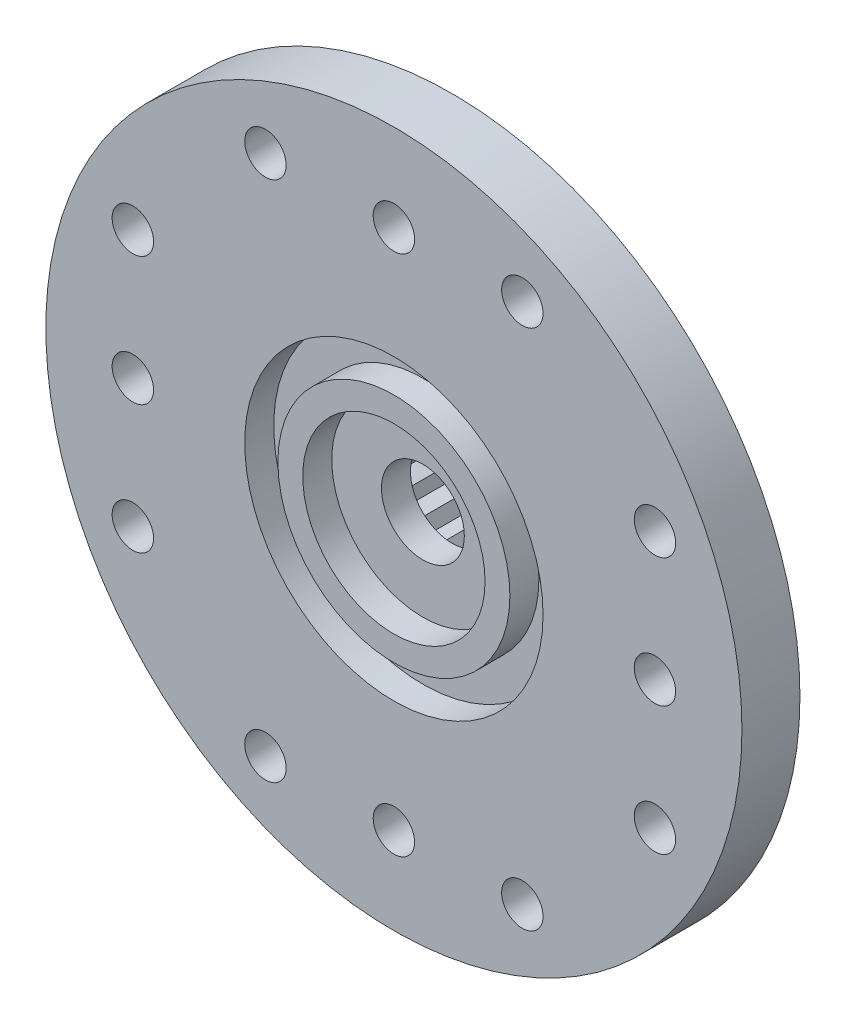
from build123d import *

# Parameters (mm, degrees)
SKETCH1_R           = 4.5000037
BOSS_EXTRUDE1_DEPTH = 3.75000012
SKETCH2_R           = 4.5000037
SKETCH2_R_2         = 3.499999998
SKETCH2_R_3         = 1.25000004
BOSS_EXTRUDE2_DEPTH = 1.750000056
SKETCH4_R           = 2.75000466
SKETCH4_R_2         = 1.25000004
CUT_EXTRUDE1_DEPTH  = 0.875000028
SKETCH6_R           = 4.5000037
SKETCH6_R_2         = 3.5000057
CUT_EXTRUDE2_DEPTH  = 0.875000028
SKETCH7_R           = 10.5000044
SKETCH7_R_2         = 4.5000037
BOSS_EXTRUDE3_DEPTH = 1.750000056
SKETCH9_R           = 0.62500002
CUT_EXTRUDE3_DEPTH  = 6.500000176
CIRPATTERN1_COUNT   = 4
CHAMFER1_SIZE       = 0.999998
CHAMFER1_SIZE2      = 0.577349114


with BuildPart() as part:
    # Sketch1 → Boss-Extrude1 (new body)
    with BuildSketch(Plane.XY):
        with Locations((-10.24995918, 0)):
            Circle(SKETCH1_R)
        Polygon((-10.24995918, 2.999994), (-10.594624819, 2.728309468), (-10.996027349, 2.905743672), (-11.262299488, 2.55687975), (-11.695217312, 2.628914782), (-11.866365092, 2.224791874), (-12.303596391, 2.186901508), (-12.368865968, 1.752912142), (-12.782937891, 1.60747717), (-12.738228138, 1.170890494), (-13.103123023, 0.927049129), (-12.951243218, 0.515297489), (-13.244033377, 0.188371182), (-12.994526687, -0.172673551), (-13.196815038, -0.562142819), (-12.865358886, -0.849794878), (-12.964434908, -1.27733532), (-12.571855902, -1.473520467), (-12.561494285, -1.912268145), (-12.132459609, -2.004659346), (-12.01331141, -2.427046129), (-11.574778889, -2.409838105), (-11.354330629, -2.789323879), (-10.933854876, -2.663597874), (-10.625958129, -2.976338151), (-10.24995918, -2.749993992), (-9.873960231, -2.976338151), (-9.566063484, -2.663597874), (-9.145587731, -2.789323879), (-8.925139471, -2.409838105), (-8.48660695, -2.427046129), (-8.367458751, -2.004659346), (-7.938424075, -1.912268145), (-7.928062458, -1.473520467), (-7.535483452, -1.27733532), (-7.634559474, -0.849794878), (-7.303103322, -0.562142819), (-7.505391673, -0.172673551), (-7.255884983, 0.188371182), (-7.548675142, 0.515297489), (-7.396795337, 0.927049129), (-7.761690222, 1.170890494), (-7.716980469, 1.60747717), (-8.131052392, 1.752912142), (-8.196321969, 2.186901508), (-8.633553268, 2.224791874), (-8.804701048, 2.628914782), (-9.237618872, 2.55687975), (-9.503891011, 2.905743672), (-9.905293541, 2.728309468), align=None, mode=Mode.SUBTRACT)
    extrude(amount=-BOSS_EXTRUDE1_DEPTH)

    # Sketch2 → Boss-Extrude2 (add)
    with BuildSketch(Plane.XY):
        with Locations((-10.24995918, 0)):
            Circle(SKETCH2_R)
        with Locations((-10.24995918, 0)):
            Circle(SKETCH2_R_2, mode=Mode.SUBTRACT)
        with Locations((-10.24995918, 0)):
            Circle(SKETCH2_R_2)
        with Locations((-10.24995918, 0)):
            Circle(SKETCH2_R_3, mode=Mode.SUBTRACT)
    extrude(amount=BOSS_EXTRUDE2_DEPTH)

    # Sketch4 → Cut-Extrude1 (cut)
    with BuildSketch(Plane.XY.offset(1.750000056)):
        with Locations((-10.24995918, 0)):
            Circle(SKETCH4_R)
        with Locations((-10.24995918, 0)):
            Circle(SKETCH4_R_2, mode=Mode.SUBTRACT)
    extrude(amount=-CUT_EXTRUDE1_DEPTH, mode=Mode.SUBTRACT)

    # Sketch6 → Cut-Extrude2 (cut)
    with BuildSketch(Plane.XY.offset(1.750000056)):
        with Locations((-10.24995918, 0)):
            Circle(SKETCH6_R)
        with Locations((-10.24995918, 0)):
            Circle(SKETCH6_R_2, mode=Mode.SUBTRACT)
    extrude(amount=-CUT_EXTRUDE2_DEPTH, mode=Mode.SUBTRACT)

    # Sketch7 → Boss-Extrude3 (add)
    with BuildSketch(Plane.XY.offset(1.750000056)):
        with Locations((-10.24995918, 0)):
            Circle(SKETCH7_R)
        with Locations((-10.24995918, 0)):
            Circle(SKETCH7_R_2, mode=Mode.SUBTRACT)
    extrude(amount=-BOSS_EXTRUDE3_DEPTH)

    # Sketch9 → Cut-Extrude3 (cut, through all)
    with BuildSketch(Plane.XY.offset(1.750000056)):
        with Locations((-10.24995918, 7.8750033)):
            Circle(SKETCH9_R)
        with Locations((-14.124959304, 7.8750033)):
            Circle(SKETCH9_R)
        with Locations((-6.374959056, 7.8750033)):
            Circle(SKETCH9_R)
    cut_extrude3 = extrude(amount=-CUT_EXTRUDE3_DEPTH, mode=Mode.SUBTRACT)

    # CirPattern1: Cut-Extrude3 ×4 about axis
    cirpattern1_axis = Axis((-10.24995918, 0, 0), (0, 0, 1))
    for i in range(1, CIRPATTERN1_COUNT):
        add(cut_extrude3.rotate(cirpattern1_axis, i * 360 / CIRPATTERN1_COUNT), mode=Mode.SUBTRACT)

    # Chamfer1
    chamfer1_edges = [part.edges().sort_by_distance(p)[0] for p in [
        (-14.74996288, 0, 0),
    ]]
    chamfer1_side = [part.faces().sort_by_distance(p)[0] for p in [
        (-14.74996288, 0, -1.87500006),
    ]]
    chamfer(chamfer1_edges, length=CHAMFER1_SIZE, length2=CHAMFER1_SIZE2, reference=chamfer1_side[0])


solid = part.part
